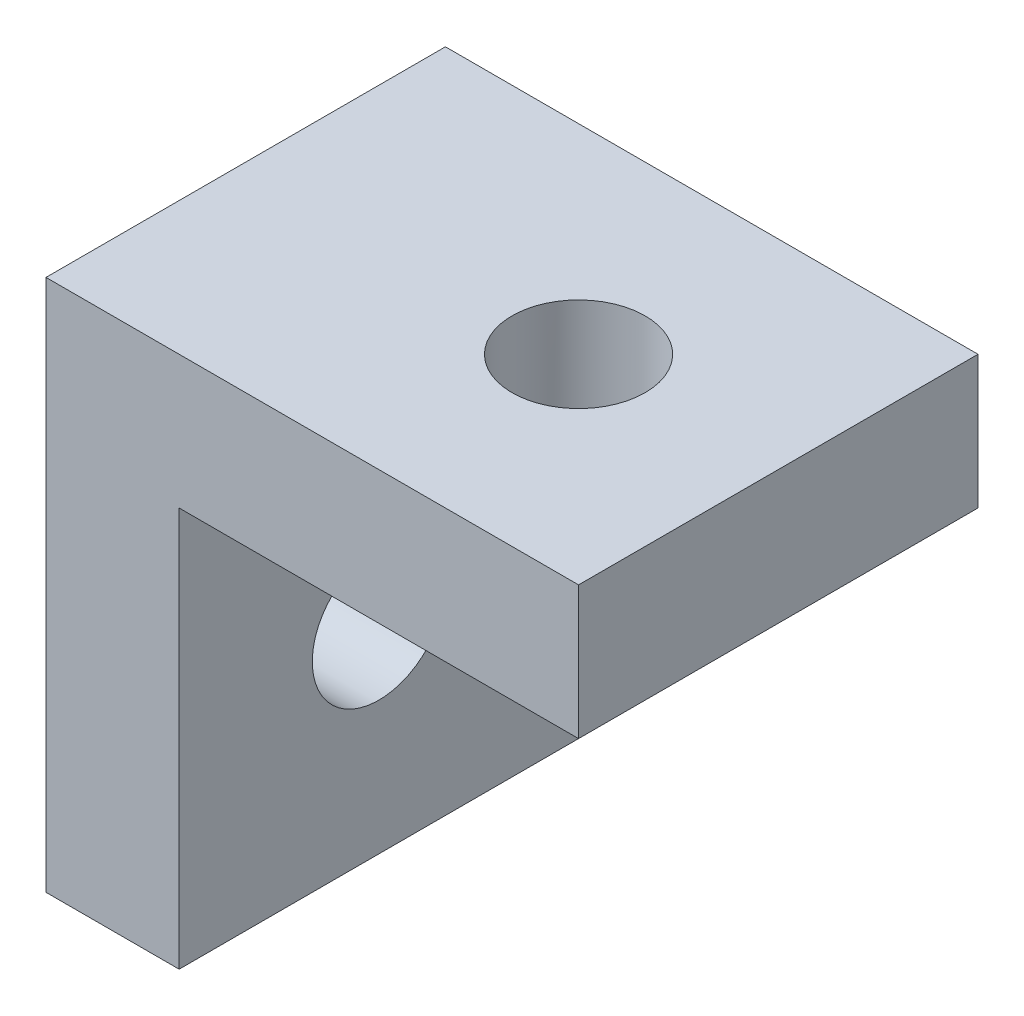
from build123d import *

# Parameters (mm, degrees)
EXTRUDE_THIN1_DEPTH     = 30
SKETCH2_R               = 5
CUT_EXTRUDE1_DEPTH      = 31
CUT_EXTRUDE1_DEPTH_BACK = 11
SKETCH3_R               = 5
CUT_EXTRUDE2_DEPTH      = 11


with BuildPart() as part:
    # Sketch1 → Extrude-Thin1 (new body)
    with BuildSketch(Plane.XY):
        Polygon((0, 0), (0, 30), (30, 30), (30, 40), (-10, 40), (-10, 0), align=None)
    extrude(amount=EXTRUDE_THIN1_DEPTH)

    # Sketch2 → Cut-Extrude1 (cut, two sides)
    with BuildSketch(Plane(origin=(0, 30, 0), x_dir=(-1, 0, 0), z_dir=(0, -1, 0))) as cut_extrude1_sk:
        with Locations((-15, -15)):
            Circle(SKETCH2_R)
    extrude(amount=CUT_EXTRUDE1_DEPTH, mode=Mode.SUBTRACT)
    extrude(cut_extrude1_sk.sketch, amount=-CUT_EXTRUDE1_DEPTH_BACK, mode=Mode.SUBTRACT)

    # Sketch3 → Cut-Extrude2 (cut, through all)
    with BuildSketch(Plane(origin=(0, 0, 0), x_dir=(0, 0, -1), z_dir=(1, 0, 0))):
        with Locations((-15, 15)):
            Circle(SKETCH3_R)
    extrude(amount=-CUT_EXTRUDE2_DEPTH, mode=Mode.SUBTRACT)


solid = part.part
